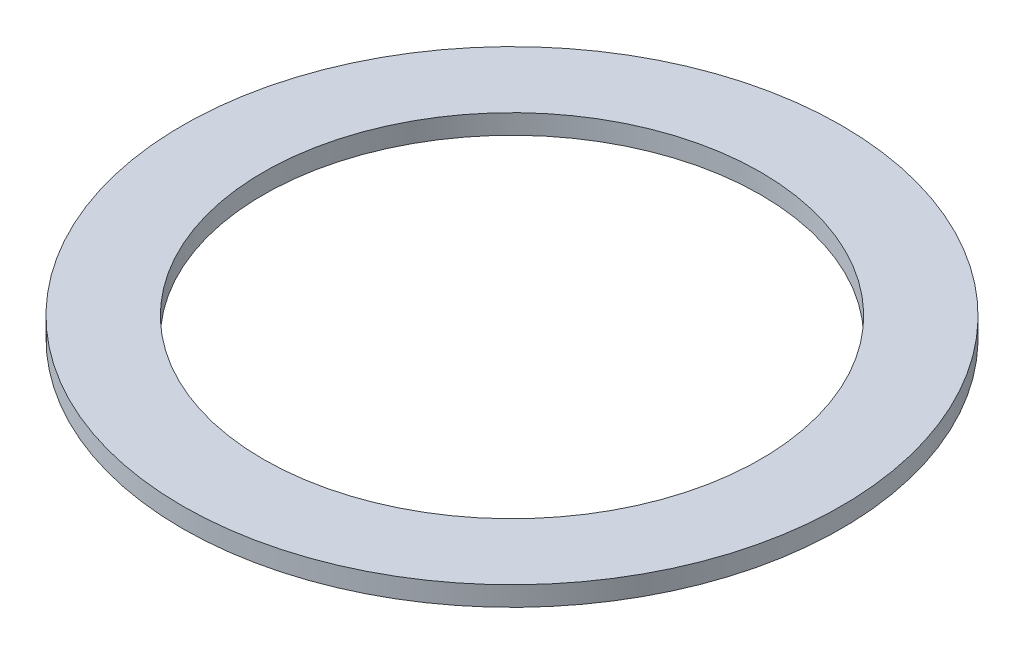
from build123d import *

# Parameters (mm, degrees)
SKETCH1_R              = 84.15
SKETCH1_R_2            = 63.5
CARBON_FELT_RING_DEPTH = 5


with BuildPart() as part:
    # Sketch1 → Carbon Felt Ring (new body)
    with BuildSketch(Plane(origin=(0, 0, 0), x_dir=(1, 0, 0), z_dir=(0, 1, 0))):
        Circle(SKETCH1_R)
        Circle(SKETCH1_R_2, mode=Mode.SUBTRACT)
    extrude(amount=CARBON_FELT_RING_DEPTH)


solid = part.part
